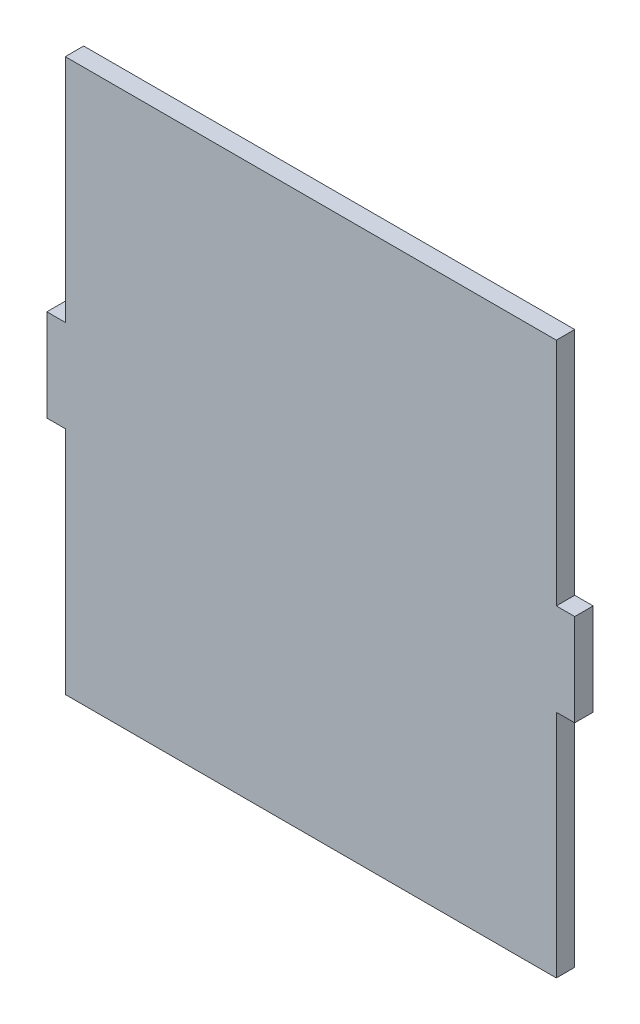
from build123d import *

# Parameters (mm, degrees)
SKETCH1_W           = 3
SKETCH1_H           = 15
SKETCH1_W_2         = 80
SKETCH1_H_2         = 90
BOSS_EXTRUDE1_DEPTH = 3


with BuildPart() as part:
    # Sketch1 → Boss-Extrude1 (new body)
    with BuildSketch(Plane.XY):
        with Locations((-41.5, 0)):
            Rectangle(SKETCH1_W, SKETCH1_H)
        Rectangle(SKETCH1_W_2, SKETCH1_H_2)
        with Locations((41.5, 0)):
            Rectangle(SKETCH1_W, SKETCH1_H)
    extrude(amount=BOSS_EXTRUDE1_DEPTH)


solid = part.part
